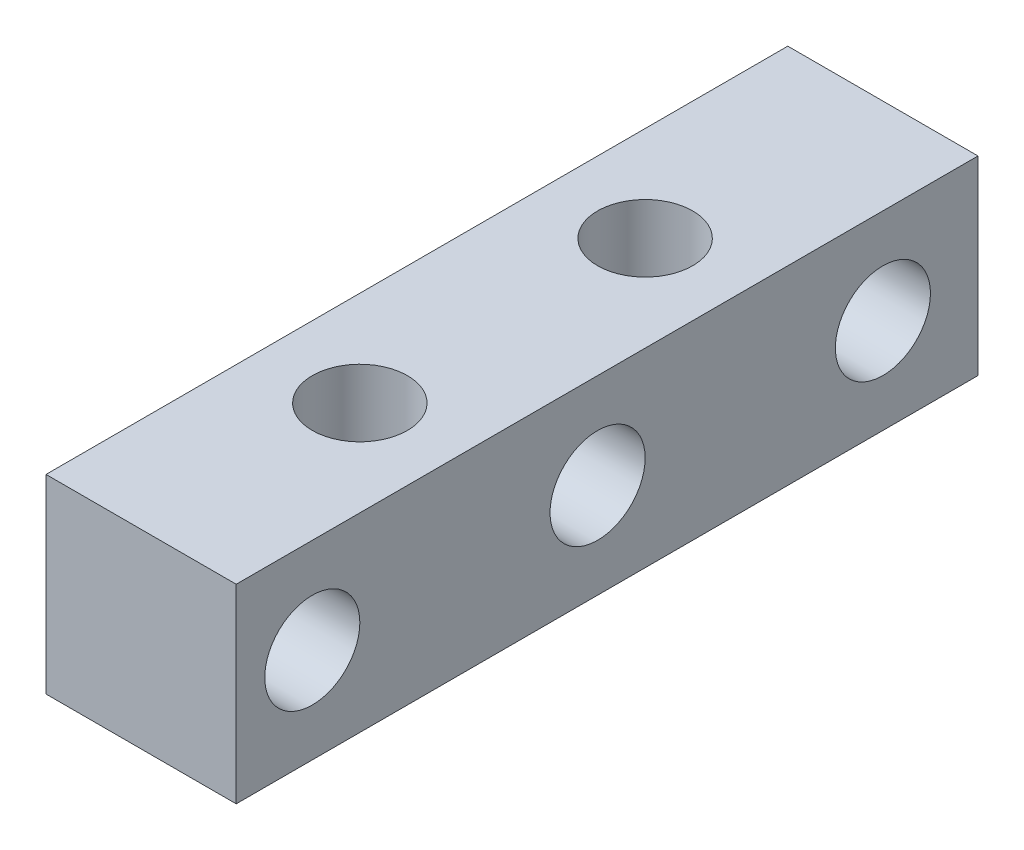
from build123d import *

# Parameters (mm, degrees)
SKETCH1_W               = 12.7
SKETCH1_H               = 12.7
BOSS_EXTRUDE1_DEPTH     = 34.925
F_1_4_20_TAPPED_HOLE1_D = 6.35
F_1_4_20_TAPPED_HOLE2_D = 6.35
SKETCH6_W               = 12.7
SKETCH6_H               = 20.32
CUT_EXTRUDE1_DEPTH      = 13.7


with BuildPart() as part:
    # Sketch1 → Boss-Extrude1 (new body, symmetric)
    with BuildSketch(Plane.XY):
        Rectangle(SKETCH1_W, SKETCH1_H)
    extrude(amount=BOSS_EXTRUDE1_DEPTH, both=True)

    # 1/4-20 Tapped Hole1 (through all)
    with Locations(Plane(origin=(0, 6.35, 0), x_dir=(1, 0, 0), z_dir=(0, 1, 0))):
        with Locations((0, 0), (0, 19.05), (0, -19.05)):
            Hole(F_1_4_20_TAPPED_HOLE1_D / 2)

    # 1/4-20 Tapped Hole2 (through all)
    with Locations(Plane(origin=(6.35, 0, 0), x_dir=(0, 0, -1), z_dir=(1, 0, 0))):
        with Locations((9.525, 0), (28.575, 0), (-9.525, 0), (-28.575, 0)):
            Hole(F_1_4_20_TAPPED_HOLE2_D / 2)

    # Sketch6 → Cut-Extrude1 (cut, through all)
    with BuildSketch(Plane(origin=(0, 6.35, 0), x_dir=(1, 0, 0), z_dir=(0, 1, 0))):
        with Locations((0, -24.765)):
            Rectangle(SKETCH6_W, SKETCH6_H)
    extrude(amount=-CUT_EXTRUDE1_DEPTH, mode=Mode.SUBTRACT)


solid = part.part
